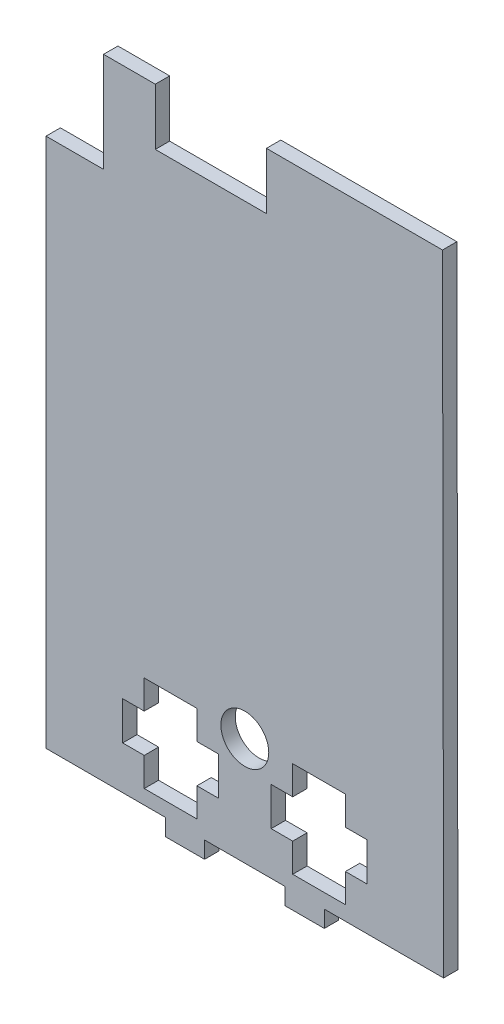
from build123d import *

# Parameters (mm, degrees)
MODEL_R                 = 5
SALIENTE_EXTRUIR1_DEPTH = 3


with BuildPart() as part:
    # Model → Saliente-Extruir1 (new body)
    with BuildSketch(Plane.XY):
        Polygon((124.511184003, 58.317312114), (112.50181664, 58.326235146), (112.501811813, 36.503581249), (112.501804141, 1.819115993), (112.501801747, -9.003305006), (112.501792152, -52.377623741), (137.401805699, -52.391743595), (137.401805699, -55.885276943), (145.601805699, -55.885276943), (145.601805699, -52.385276943), (162.401805699, -52.385276943), (162.401805699, -55.885276943), (170.601805699, -55.885276943), (170.601805699, -52.385276943), (195.501819246, -52.392930144), (195.275424073, 79.124358077), (158.510749751, 79.124374738), (158.510749751, 67.325142582), (135.310749751, 67.32643696), (135.310749751, 79.124374745), (124.511184003, 79.124374745), align=None)
        Polygon((144.00179591, -43.389548344), (144.00179591, -49.389548344), (133.00179591, -49.389548344), (133.00179591, -43.389548344), (128.50179591, -43.389548344), (128.50179591, -35.389548344), (133.00179591, -35.389548344), (133.00179591, -29.389548344), (144.00179591, -29.389548344), (144.00179591, -35.389548344), (148.50179591, -35.389548344), (148.50179591, -43.389548344), align=None, mode=Mode.SUBTRACT)
        with Locations((154.001805699, -29.885276943)):
            Circle(MODEL_R, mode=Mode.SUBTRACT)
        Polygon((175.001819246, -43.389558962), (175.001819246, -49.389558962), (164.001819246, -49.389558962), (164.001819246, -43.389558962), (159.501819246, -43.389558962), (159.501819246, -35.389558962), (164.001819246, -35.389558962), (164.001819246, -29.389558962), (175.001819246, -29.389558962), (175.001819246, -35.389558962), (179.501819246, -35.389558962), (179.501819246, -43.389558962), align=None, mode=Mode.SUBTRACT)
    extrude(amount=SALIENTE_EXTRUIR1_DEPTH)


solid = part.part
